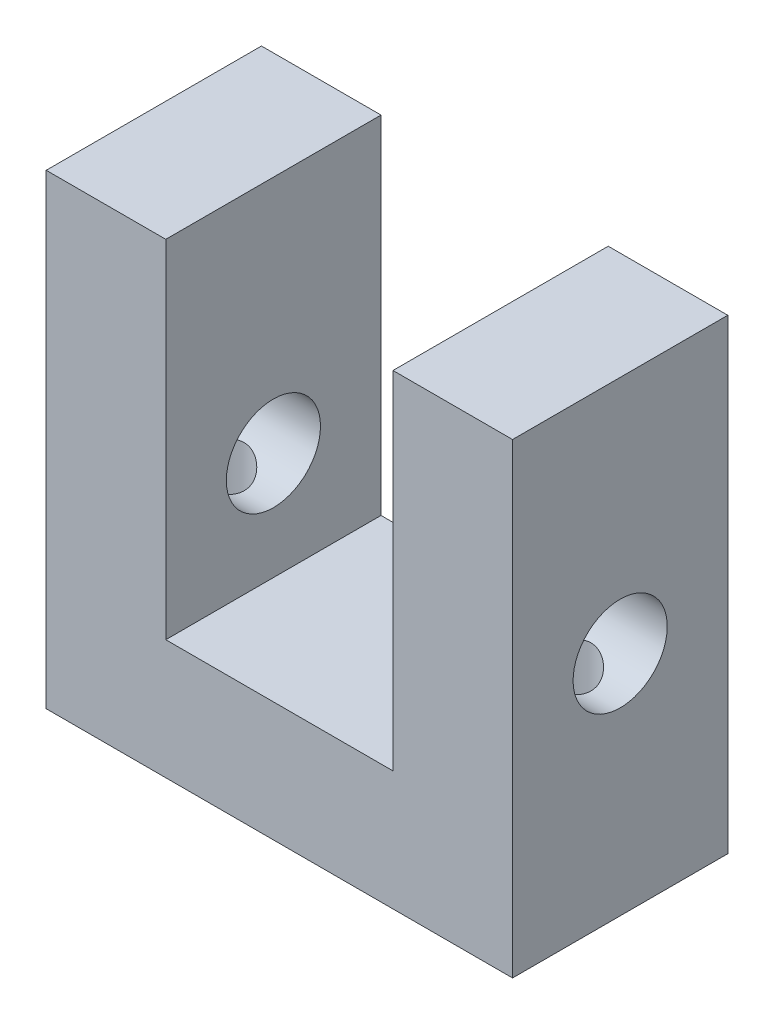
from build123d import *

# Parameters (mm, degrees)
BOSS_EXTRUDE1_DEPTH         = 18
SKETCH3_R                   = 3.937
CUT_EXTRUDE1_DEPTH          = 40
F_1_4_20_TAPPED_HOLE1_D     = 5.1054
F_1_4_20_TAPPED_HOLE1_DEPTH = 19.05
F_1_4_20_TAPPED_HOLE1_TIP   = 1.533816902


with BuildPart() as part:
    # Sketch1 → Boss-Extrude1 (new body)
    with BuildSketch(Plane.XY):
        Polygon((-19.5, 0), (19.5, 0), (19.5, 39), (9.5, 39), (9.5, 10), (-9.5, 10), (-9.5, 39), (-19.5, 39), align=None)
    extrude(amount=BOSS_EXTRUDE1_DEPTH)

    # Sketch3 → Cut-Extrude1 (cut, through all)
    with BuildSketch(Plane(origin=(19.5, 0, 0), x_dir=(0, 0, -1), z_dir=(1, 0, 0))):
        with Locations((-9, 19)):
            Circle(SKETCH3_R)
    extrude(amount=-CUT_EXTRUDE1_DEPTH, mode=Mode.SUBTRACT)

    # 1/4-20 Tapped Hole1
    with Locations(Plane(origin=(0, 0, 0), x_dir=(-1, 0, 0), z_dir=(0, -1, 0))):
        with Locations((-14.5, -9), (14.5, -9)):
            Hole(F_1_4_20_TAPPED_HOLE1_D / 2, depth=F_1_4_20_TAPPED_HOLE1_DEPTH)
            with Locations((0, 0, -(F_1_4_20_TAPPED_HOLE1_DEPTH + F_1_4_20_TAPPED_HOLE1_TIP / 2))):  # 118° drill point
                Cone(0, F_1_4_20_TAPPED_HOLE1_D / 2, F_1_4_20_TAPPED_HOLE1_TIP, mode=Mode.SUBTRACT)


solid = part.part
